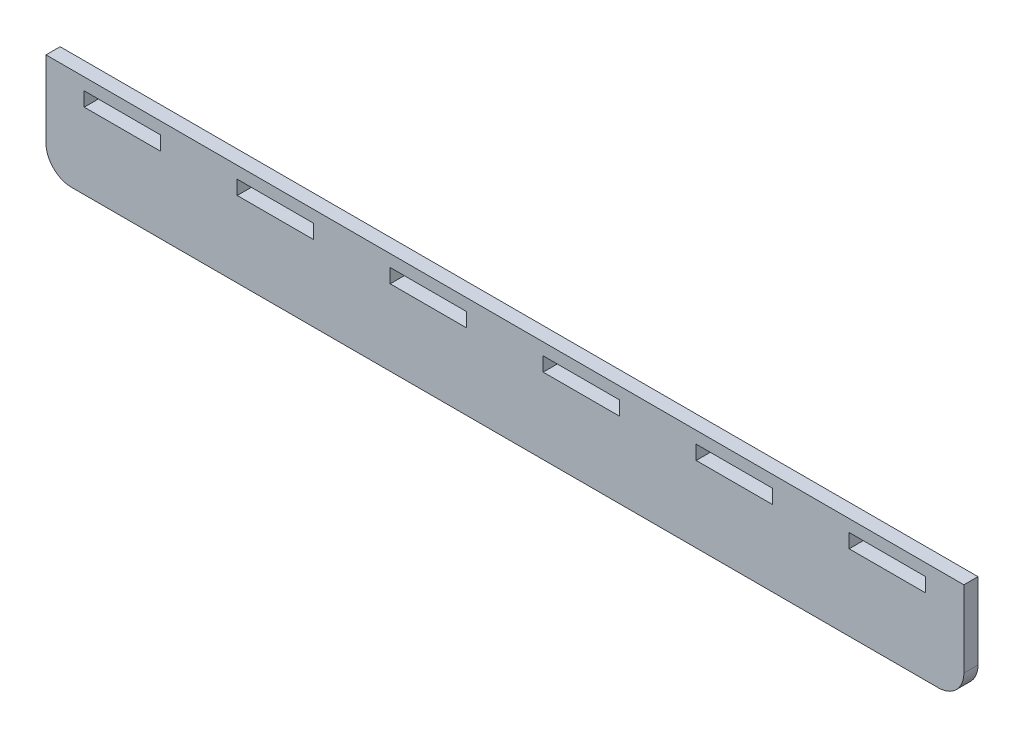
from build123d import *

# Parameters (mm, degrees)
SKETCH2_W           = 360
SKETCH2_H           = 40
SKETCH2_W_2         = 30
SKETCH2_H_2         = 5.54
BOSS_EXTRUDE1_DEPTH = 5.54
FILLET1_R           = 10


with BuildPart() as part:
    # Sketch2 → Boss-Extrude1 (new body)
    with BuildSketch(Plane.XY):
        with Locations((239.474602118, -4.853960239)):
            Rectangle(SKETCH2_W, SKETCH2_H)
        with Locations((89.474602118, 7.646039761)):
            Rectangle(SKETCH2_W_2, SKETCH2_H_2, mode=Mode.SUBTRACT)
        with Locations((149.474602118, 7.646039761)):
            Rectangle(SKETCH2_W_2, SKETCH2_H_2, mode=Mode.SUBTRACT)
        with Locations((209.474602118, 7.646039761)):
            Rectangle(SKETCH2_W_2, SKETCH2_H_2, mode=Mode.SUBTRACT)
        with Locations((269.474602118, 7.646039761)):
            Rectangle(SKETCH2_W_2, SKETCH2_H_2, mode=Mode.SUBTRACT)
        with Locations((329.474602118, 7.646039761)):
            Rectangle(SKETCH2_W_2, SKETCH2_H_2, mode=Mode.SUBTRACT)
        with Locations((389.474602118, 7.646039761)):
            Rectangle(SKETCH2_W_2, SKETCH2_H_2, mode=Mode.SUBTRACT)
    extrude(amount=BOSS_EXTRUDE1_DEPTH)

    # Fillet1
    fillet1_edges = [part.edges().sort_by_distance(p)[0] for p in [
        (419.474602118, -24.853960239, 2.77),
        (59.474602118, -24.853960239, 2.77),
    ]]
    fillet(fillet1_edges, radius=FILLET1_R)


solid = part.part
